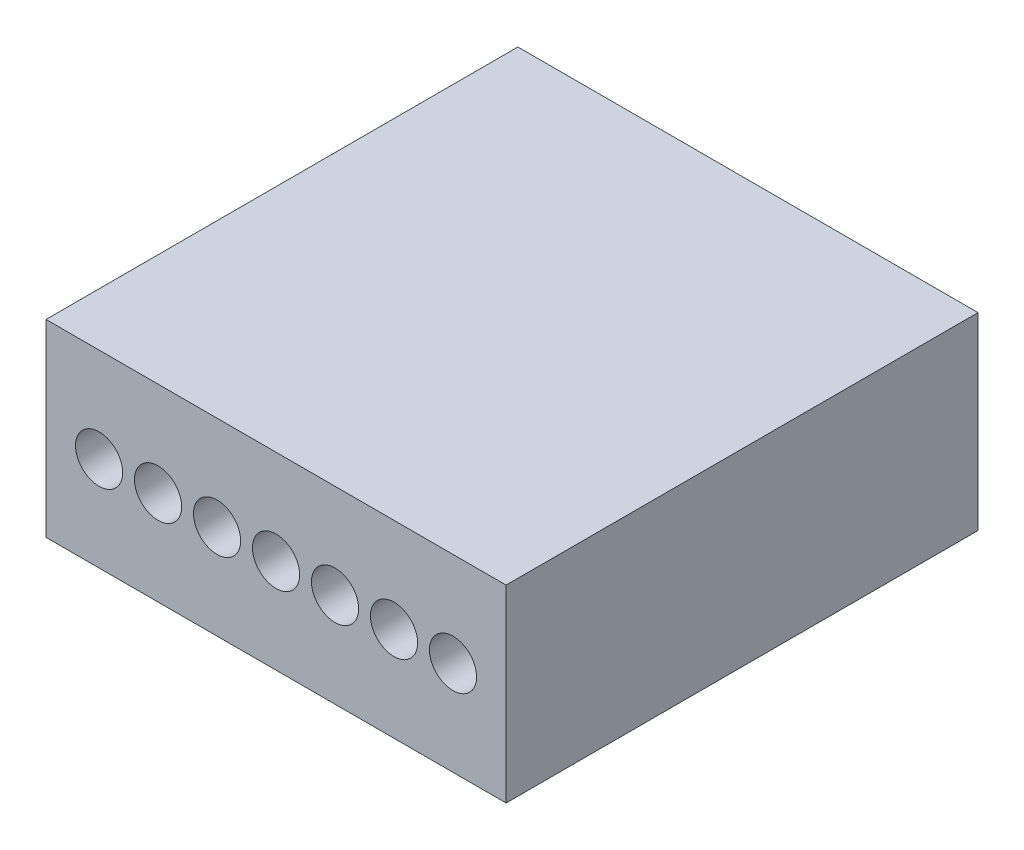
from build123d import *

# Parameters (mm, degrees)
SKETCH2_W           = 9.75
SKETCH2_H           = 4
BOSS_EXTRUDE1_DEPTH = 10
SKETCH3_R           = 0.5
CUT_EXTRUDE1_DEPTH  = 5


with BuildPart() as part:
    # Sketch2 → Boss-Extrude1 (new body)
    with BuildSketch(Plane.XY):
        with Locations((4.875, 2)):
            Rectangle(SKETCH2_W, SKETCH2_H)
    extrude(amount=BOSS_EXTRUDE1_DEPTH)

    # Sketch3 → Cut-Extrude1 (cut)
    with BuildSketch(Plane.XY.offset(10)):
        with Locations((1.125, 2)):
            Circle(SKETCH3_R)
        with Locations((2.375, 2)):
            Circle(SKETCH3_R)
        with Locations((3.625, 2)):
            Circle(SKETCH3_R)
        with Locations((4.875, 2)):
            Circle(SKETCH3_R)
        with Locations((6.125, 2)):
            Circle(SKETCH3_R)
        with Locations((7.375, 2)):
            Circle(SKETCH3_R)
        with Locations((8.625, 2)):
            Circle(SKETCH3_R)
    extrude(amount=-CUT_EXTRUDE1_DEPTH, mode=Mode.SUBTRACT)


solid = part.part
